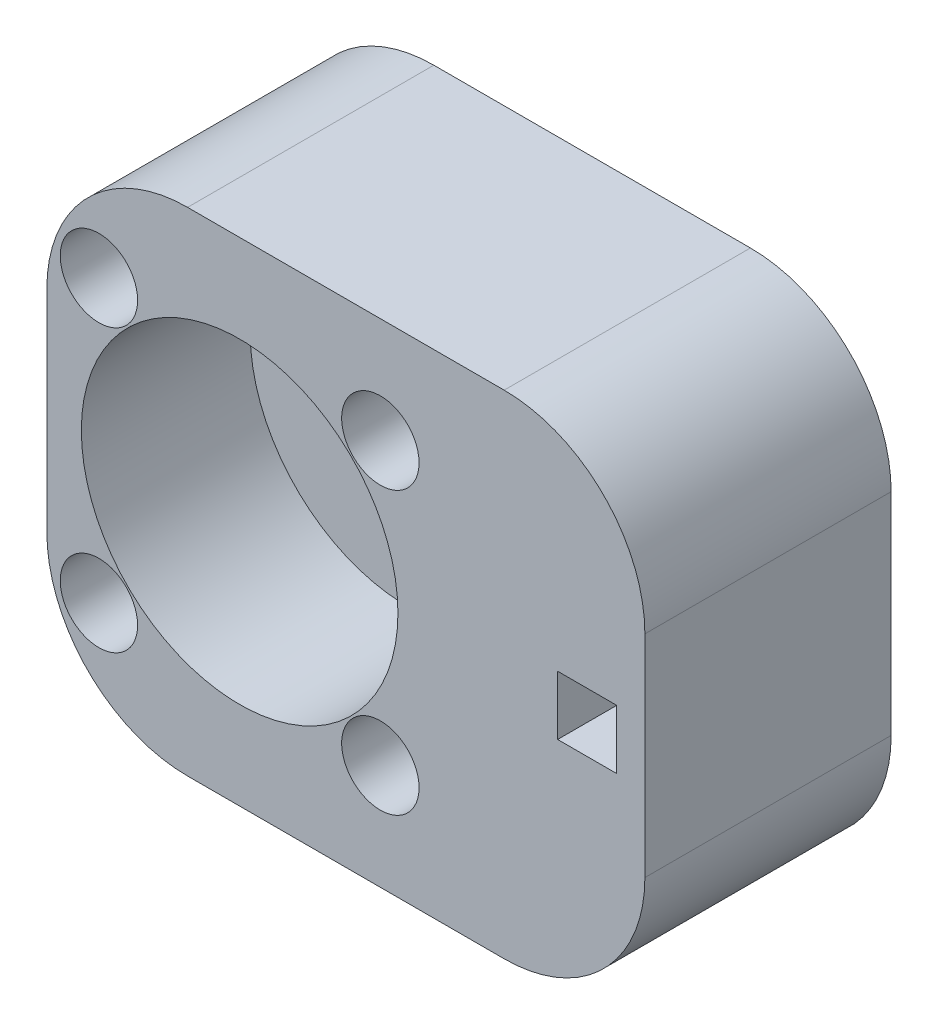
from build123d import *

# Parameters (mm, degrees)
SKETCH1_W           = 42.5
SKETCH1_H           = 35
BOSS_EXTRUDE1_DEPTH = 17.5
SKETCH3_W           = 4.2
SKETCH3_H           = 4.2
CUT_EXTRUDE1_DEPTH  = 12.5
SKETCH4_R           = 1.599999998
SKETCH4_R_2         = 1.6
CUT_EXTRUDE2_DEPTH  = 18.5
SKETCH5_R           = 2.75
CUT_EXTRUDE3_DEPTH  = 15
SKETCH6_R           = 11.25
CUT_EXTRUDE4_DEPTH  = 12
FILLET1_R           = 10


with BuildPart() as part:
    # Sketch1 → Boss-Extrude1 (new body)
    with BuildSketch(Plane.XY):
        with Locations((380.000010525, -96.878222963)):
            Rectangle(SKETCH1_W, SKETCH1_H)
    extrude(amount=BOSS_EXTRUDE1_DEPTH)

    # Sketch3 → Cut-Extrude1 (cut)
    with BuildSketch(Plane.XY.offset(17.5)):
        with Locations((397.150010525, -96.878222963)):
            Rectangle(SKETCH3_W, SKETCH3_H)
    extrude(amount=-CUT_EXTRUDE1_DEPTH, mode=Mode.SUBTRACT)

    # Sketch4 → Cut-Extrude2 (cut, through all)
    with BuildSketch(Plane.XY.offset(17.5)):
        with Locations((382.450010525, -86.878222963)):
            Circle(SKETCH4_R)
        with Locations((382.450010525, -106.878222963)):
            Circle(SKETCH4_R_2)
        with Locations((362.450010525, -86.878222963)):
            Circle(SKETCH4_R)
        with Locations((362.450010525, -106.878222963)):
            Circle(SKETCH4_R_2)
    extrude(amount=-CUT_EXTRUDE2_DEPTH, mode=Mode.SUBTRACT)

    # Sketch5 → Cut-Extrude3 (cut)
    with BuildSketch(Plane.XY.offset(17.5)):
        with Locations((382.450010525, -106.878222963)):
            Circle(SKETCH5_R)
        with Locations((382.450010525, -86.878222963)):
            Circle(SKETCH5_R)
        with Locations((362.450010525, -86.878222963)):
            Circle(SKETCH5_R)
        with Locations((362.450010525, -106.878222963)):
            Circle(SKETCH5_R)
    extrude(amount=-CUT_EXTRUDE3_DEPTH, mode=Mode.SUBTRACT)

    # Sketch6 → Cut-Extrude4 (cut)
    with BuildSketch(Plane.XY.offset(17.5)):
        with Locations((372.450010525, -96.878222963)):
            Circle(SKETCH6_R)
    extrude(amount=-CUT_EXTRUDE4_DEPTH, mode=Mode.SUBTRACT)

    # Fillet1
    fillet1_edges = [part.edges().sort_by_distance(p)[0] for p in [
        (401.250010525, -114.378222963, 8.75),
        (358.750010525, -114.378222963, 8.75),
        (358.750010525, -79.378222963, 8.75),
        (401.250010525, -79.378222963, 8.75),
    ]]
    fillet(fillet1_edges, radius=FILLET1_R)


solid = part.part
